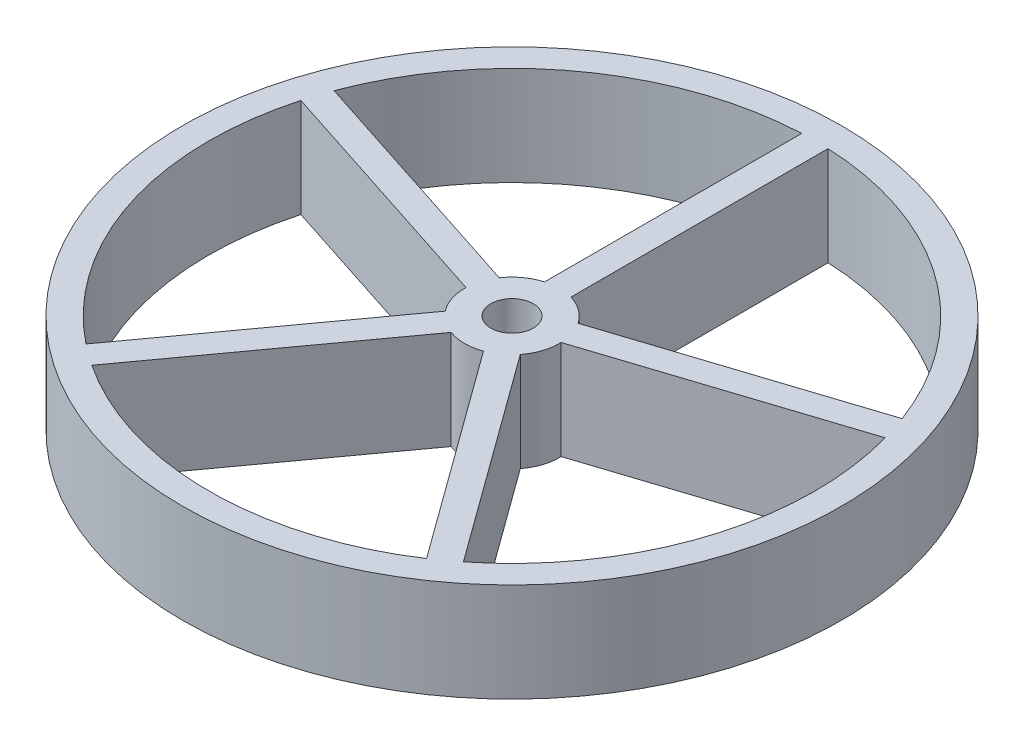
from build123d import *

# Parameters (mm, degrees)
SKETCH1_R           = 25
SKETCH1_R_2         = 1.61
BOSS_EXTRUDE1_DEPTH = 7.5
CUT_EXTRUDE2_DEPTH  = 10


with BuildPart() as part:
    # Sketch1 → Boss-Extrude1 (new body)
    with BuildSketch(Plane(origin=(0, 0, 0), x_dir=(1, 0, 0), z_dir=(0, 1, 0))):
        Circle(SKETCH1_R)
        Circle(SKETCH1_R_2, mode=Mode.SUBTRACT)
    extrude(amount=BOSS_EXTRUDE1_DEPTH)

    # Sketch2 → Cut-Extrude2 (cut)
    with BuildSketch(Plane(origin=(0, 7.5, 0), x_dir=(1, 0, 0), z_dir=(0, 1, 0))):
        with BuildLine():
            Line((-1, 3.468731757), (-1, 22.978250586))
            ThreePointArc((-1, 22.978250586), (-13.519060803, 18.607390871), (-21.544597959, 8.051726448))
            Line((-21.544597959, 8.051726448), (-2.989942946, 2.022953578))
            ThreePointArc((-2.989942946, 2.022953578), (-2.121904761, 2.92055135), (-1, 3.468731757))
        make_face()
        with BuildLine():
            ThreePointArc((21.544597959, 8.051726448), (13.519060803, 18.607390871), (1, 22.978250586))
            Line((1, 22.978250586), (1, 3.468731757))
            ThreePointArc((1, 3.468731757), (2.121904761, 2.92055135), (2.989942946, 2.022953578))
            Line((2.989942946, 2.022953578), (21.544597959, 8.051726448))
        make_face()
        with BuildLine():
            ThreePointArc((23, 0), (22.789696518, 3.103181046), (22.162631947, 6.149613416))
            Line((22.162631947, 6.149613416), (3.607976935, 0.120840545))
            ThreePointArc((3.607976935, 0.120840545), (3.609494198, 0.060428739), (3.61, 0))
            ThreePointArc((3.61, 0), (3.41415947, -1.172866195), (2.847886365, -2.218477688))
            Line((2.847886365, -2.218477688), (14.315293812, -18.002009973))
            ThreePointArc((14.315293812, -18.002009973), (20.715353698, -9.993704076), (23, 0))
        make_face()
        with BuildLine():
            Line((-1.229852376, -3.394048192), (-12.697259824, -19.177580477))
            ThreePointArc((-12.697259824, -19.177580477), (0, -23), (12.697259824, -19.177580477))
            Line((12.697259824, -19.177580477), (1.229852376, -3.394048192))
            ThreePointArc((1.229852376, -3.394048192), (0, -3.61), (-1.229852376, -3.394048192))
        make_face()
        with BuildLine():
            Line((-3.607976935, 0.120840545), (-22.162631947, 6.149613416))
            ThreePointArc((-22.162631947, 6.149613416), (-21.874299875, -7.107390871), (-14.315293812, -18.002009973))
            Line((-14.315293812, -18.002009973), (-2.847886365, -2.218477688))
            ThreePointArc((-2.847886365, -2.218477688), (-3.433314024, -1.11555135), (-3.607976935, 0.120840545))
        make_face()
    extrude(amount=-CUT_EXTRUDE2_DEPTH, mode=Mode.SUBTRACT)


solid = part.part
